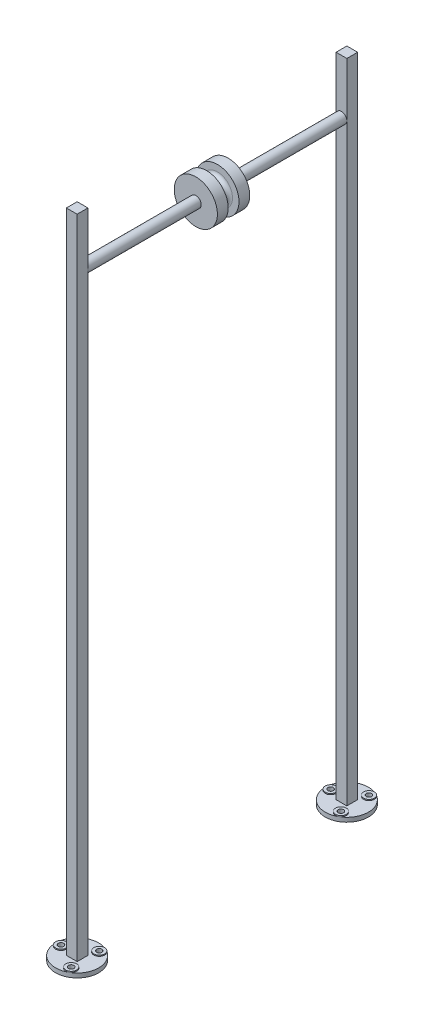
from build123d import *

# Parameters (mm, degrees)
SKETCH1_R             = 50.8
SKETCH1_R_2           = 6.35
BOSS_EXTRUDE1_DEPTH   = 10.16
BOSS_EXTRUDE1_2_DEPTH = 10.16
SKETCH2_W             = 25.4
SKETCH2_H             = 25.4
BOSS_EXTRUDE2_DEPTH   = 1524
SKETCH3_R             = 12.7
SKETCH8_R             = 12.7
SKETCH8_R_2           = 6.35
BOSS_EXTRUDE3_DEPTH   = 2.54


with BuildPart() as part:
    # Sketch1 → Boss-Extrude1 (new body)
    with BuildSketch(Plane(origin=(0, 0, 0), x_dir=(1, 0, 0), z_dir=(0, 1, 0))):
        with Locations((0, 317.5)):
            Circle(SKETCH1_R)
        with Locations((-38.1, 317.5)):
            Circle(SKETCH1_R_2, mode=Mode.SUBTRACT)
        with Locations((19.05, 350.495567884)):
            Circle(SKETCH1_R_2, mode=Mode.SUBTRACT)
        with Locations((19.05, 284.504432116)):
            Circle(SKETCH1_R_2, mode=Mode.SUBTRACT)
    extrude(amount=BOSS_EXTRUDE1_DEPTH)



with BuildPart() as body_2:
    # Sketch1 → Boss-Extrude1 2 (new body)
    with BuildSketch(Plane(origin=(0, 0, 0), x_dir=(1, 0, 0), z_dir=(0, 1, 0))):
        with Locations((0, -317.5)):
            Circle(SKETCH1_R)
        with Locations((19.05, -284.504432116)):
            Circle(SKETCH1_R_2, mode=Mode.SUBTRACT)
        with Locations((19.05, -350.495567884)):
            Circle(SKETCH1_R_2, mode=Mode.SUBTRACT)
        with Locations((-38.1, -317.5)):
            Circle(SKETCH1_R_2, mode=Mode.SUBTRACT)
    extrude(amount=BOSS_EXTRUDE1_2_DEPTH)


with BuildPart() as part_1:
    add(part.part)

    add(body_2.part)  # Boss-Extrude2 merges body 2
    # Sketch2 → Boss-Extrude2 (add)
    with BuildSketch(Plane(origin=(0, 10.16, 0), x_dir=(1, 0, 0), z_dir=(0, 1, 0))):
        with Locations((0, 317.5)):
            Rectangle(SKETCH2_W, SKETCH2_H)
        with Locations((0, -317.5)):
            Rectangle(SKETCH2_W, SKETCH2_H)
    extrude(amount=BOSS_EXTRUDE2_DEPTH)

    # Sweep1: sweep along a path in Sketch5
    with BuildLine(Plane(origin=(0, 0, 0), x_dir=(0, 0, -1), z_dir=(1, 0, 0))) as sweep1_path:
        Line((-304.8, 1407.16), (304.8, 1407.16))
    # Sketch3 → Sweep1 (sweep)
    with BuildSketch(Plane(origin=(0, 0, 304.8), x_dir=(-1, 0, 0), z_dir=(0, 0, -1))):
        with Locations((0, 1407.16)):
            Circle(SKETCH3_R)
    sweep(path=sweep1_path.line)

    # Sketch7 → Revolve2 (revolve)
    with BuildSketch(Plane(origin=(0, 0, 0), x_dir=(0, 0, -1), z_dir=(1, 0, 0))):
        with BuildLine():
            Line((-38.1, 1419.86), (-38.1, 1457.96))
            Line((-38.1, 1457.96), (-12.7, 1457.96))
            Line((-12.7, 1457.96), (-12.7, 1442.72))
            ThreePointArc((-12.7, 1442.72), (-9.724204897, 1435.535795103), (-2.54, 1432.56))
            Line((-2.54, 1432.56), (2.54, 1432.56))
            ThreePointArc((2.54, 1432.56), (9.724204897, 1435.535795103), (12.7, 1442.72))
            Line((12.7, 1442.72), (12.7, 1457.96))
            Line((12.7, 1457.96), (38.1, 1457.96))
            Line((38.1, 1457.96), (38.1, 1419.86))
            Line((38.1, 1419.86), (-38.1, 1419.86))
        make_face()
    revolve(axis=Axis((0, 1407.16, 304.8), (0, 0, -1)))

    # Sketch8 → Boss-Extrude3 (add)
    with BuildSketch(Plane(origin=(0, 10.16, 0), x_dir=(1, 0, 0), z_dir=(0, 1, 0))):
        with Locations((-38.1, -317.5)):
            Circle(SKETCH8_R)
        with Locations((-38.1, -317.5)):
            Circle(SKETCH8_R_2, mode=Mode.SUBTRACT)
        with Locations((19.05, -284.504432116)):
            Circle(SKETCH8_R)
        with Locations((19.05, -284.504432116)):
            Circle(SKETCH8_R_2, mode=Mode.SUBTRACT)
        with Locations((19.05, -350.495567884)):
            Circle(SKETCH8_R)
        with Locations((19.05, -350.495567884)):
            Circle(SKETCH8_R_2, mode=Mode.SUBTRACT)
        with Locations((19.05, 350.495567884)):
            Circle(SKETCH8_R)
        with Locations((19.05, 350.495567884)):
            Circle(SKETCH8_R_2, mode=Mode.SUBTRACT)
        with Locations((19.05, 284.504432116)):
            Circle(SKETCH8_R)
        with Locations((19.05, 284.504432116)):
            Circle(SKETCH8_R_2, mode=Mode.SUBTRACT)
        with Locations((-38.1, 317.5)):
            Circle(SKETCH8_R)
        with Locations((-38.1, 317.5)):
            Circle(SKETCH8_R_2, mode=Mode.SUBTRACT)
    extrude(amount=BOSS_EXTRUDE3_DEPTH)


solid = part_1.part
